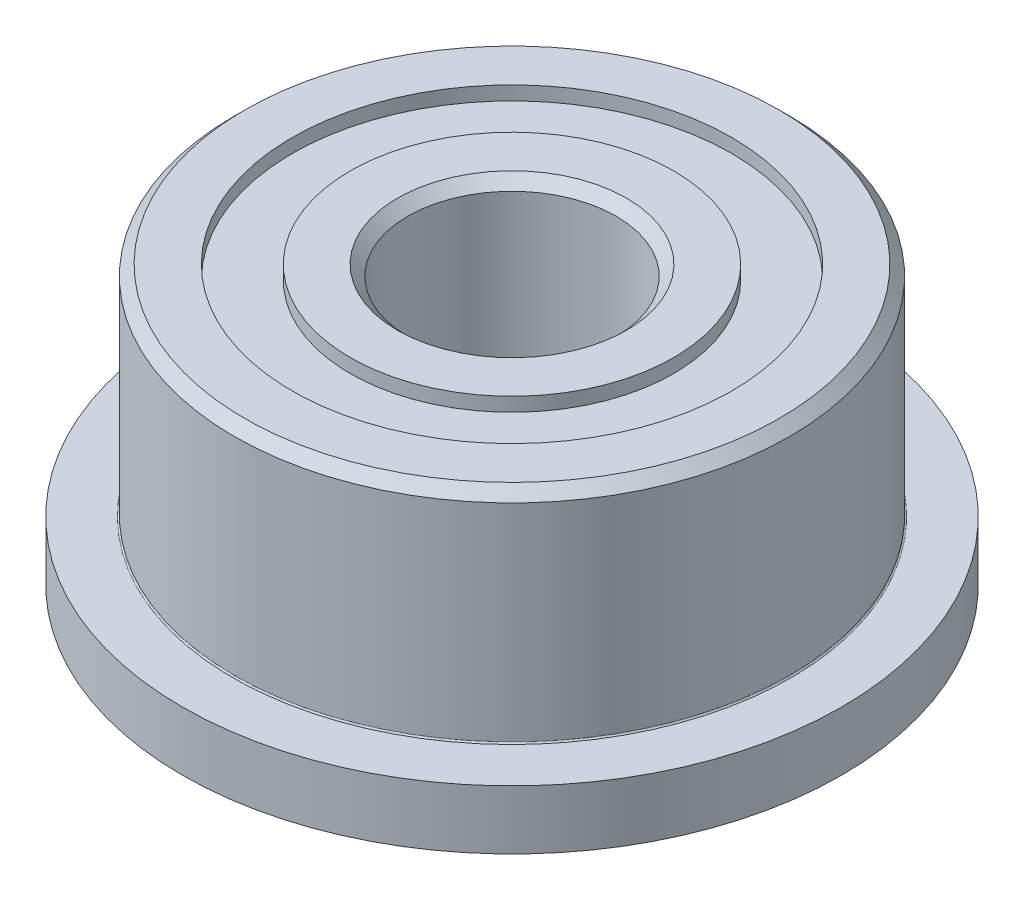
from build123d import *


with BuildPart() as part:
    # Sketch1 → Revolve1 (revolve)
    with BuildSketch(Plane.XY.offset(50.574795706)):
        with BuildLine():
            Line((-85.268115745, -0.65), (-84.433115745, -0.65))
            Line((-84.433115745, -0.65), (-84.433115745, -0.85))
            Line((-84.433115745, -0.85), (-82.848115745, -0.85))
            Line((-82.848115745, -0.85), (-82.848115745, 0))
            Line((-82.848115745, 0), (-83.578115745, 0))
            add(Edge.make_bspline(
                [(-83.578115745, 0), (-83.578115745, -0.024636788), (-83.622752532, 0.02), (-83.598115745, 0.02)],
                knots=[0, 0, 0, 0, 1, 1, 1, 1], degree=3))
            Line((-83.598115745, 0.02), (-83.598115745, 3))
            Line((-83.598115745, 3), (-83.748115745, 3.15))
            Line((-83.748115745, 3.15), (-84.433115745, 3.15))
            Line((-84.433115745, 3.15), (-84.433115745, 2.95))
            Line((-84.433115745, 2.95), (-85.268115745, 2.95))
            Line((-85.268115745, 2.95), (-85.268115745, 3.15))
            Line((-85.268115745, 3.15), (-85.948115745, 3.15))
            Line((-85.948115745, 3.15), (-86.098115745, 3))
            Line((-86.098115745, 3), (-86.098115745, -0.7))
            Line((-86.098115745, -0.7), (-85.948115745, -0.85))
            Line((-85.948115745, -0.85), (-85.268115745, -0.85))
            Line((-85.268115745, -0.85), (-85.268115745, -0.65))
        make_face()
    revolve(axis=Axis((-87.598115745, 3.15, 50.574795706), (0, -1, 0)))


solid = part.part
